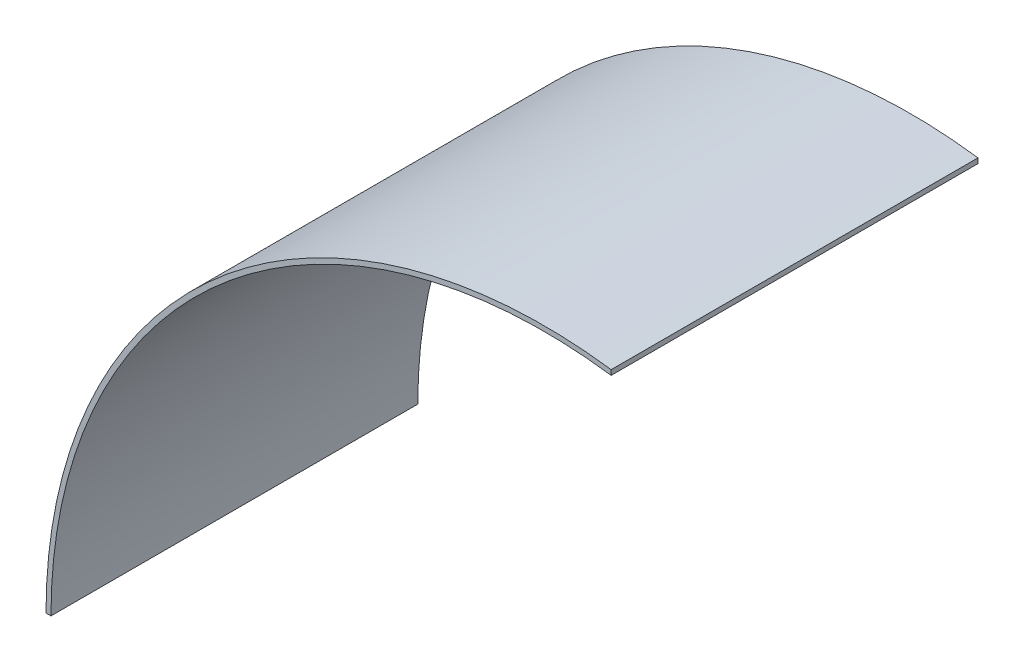
from build123d import *

# Parameters (mm, degrees)
INNER_RING_LEFT_SIDE_DEPTH = 112.268


with BuildPart() as part:
    # Sketch1 → Inner Ring - Left Side (new body)
    with BuildSketch(Plane.XY):
        with BuildLine():
            Line((20.56892, 151.005561255), (20.56892, 149.47247182))
            ThreePointArc((20.56892, 149.47247182), (-99.150490261, 113.728978642), (-150.88108, 0))
            Line((-150.88108, 0), (-152.4, 0))
            ThreePointArc((-152.4, 0), (-100.227382965, 114.805190231), (20.56892, 151.005561255))
        make_face()
    extrude(amount=INNER_RING_LEFT_SIDE_DEPTH)


solid = part.part
